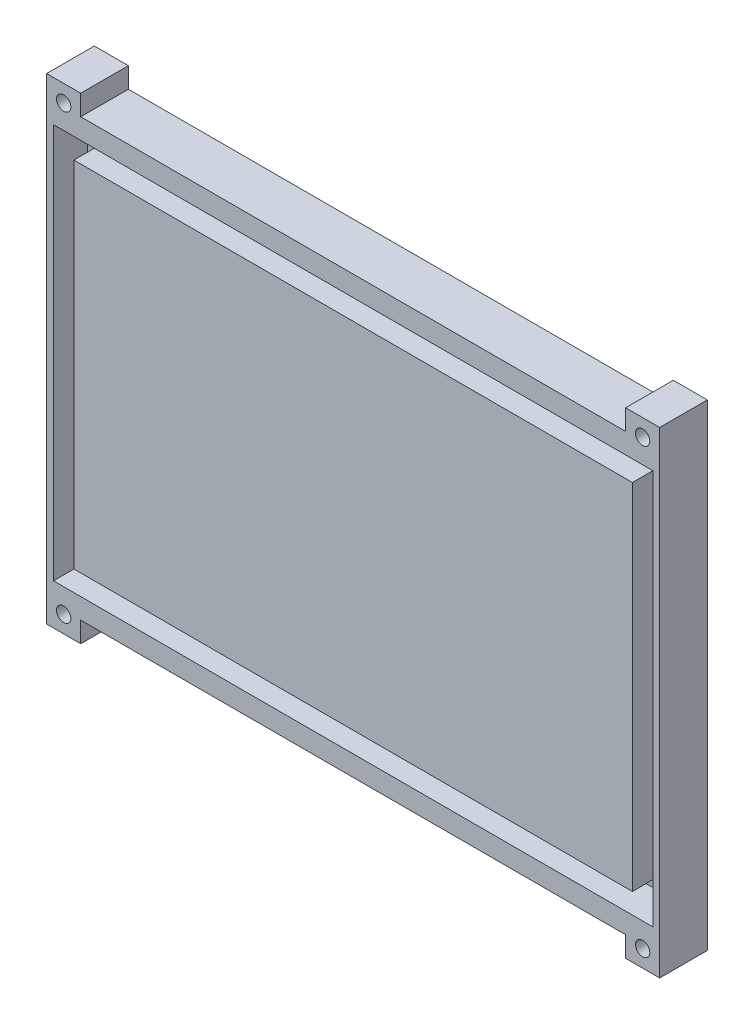
from build123d import *

# Parameters (mm, degrees)
SKETCH_1_W           = 100
SKETCH_1_H           = 70
EXTRUDE_1_DEPTH      = 10
SKETCH_6_W           = 5
SKETCH_6_H           = 5
CUT_EXTRUDE_4_DEPTH  = 5
SKETCH_7_W           = 5
SKETCH_7_H           = 5
CUT_EXTRUDE_5_DEPTH  = 3
SKETCH_8_R           = 1.05
CUT_EXTRUDE_6_DEPTH  = 42
SKETCH_10_W          = 100
SKETCH_10_H          = 70
CUT_EXTRUDE_7_DEPTH  = 3
SKETCH_11_W          = 7
SKETCH_11_H          = 70
CUT_EXTRUDE_8_DEPTH  = 5
SKETCH_12_W          = 7
SKETCH_12_H          = 70
CUT_EXTRUDE_9_DEPTH  = 5
SKETCH_15_W          = 88
SKETCH_15_H          = 58
SKETCH_15_W_2        = 82
SKETCH_15_H_2        = 52
CUT_EXTRUDE_12_DEPTH = 5
SKETCH_16_W          = 5
SKETCH_16_H          = 5
SKETCH_16_R          = 1.05
EXTRUDE_2_DEPTH      = 5
SKETCH_18_W          = 80
SKETCH_18_H          = 3
CUT_EXTRUDE_13_DEPTH = 10


with BuildPart() as part:
    # 草圖1 → 填料-伸長1 (new body)
    with BuildSketch(Plane.XY):
        with Locations((-39.08671555, 7.98136646)):
            Rectangle(SKETCH_1_W, SKETCH_1_H)
    extrude(amount=EXTRUDE_1_DEPTH)

    # 草圖6 → 除料-伸長4 (cut)
    with BuildSketch(Plane.XY.offset(10)):
        with Locations((3.41328445, 40.48136646)):
            Rectangle(SKETCH_6_W, SKETCH_6_H)
        with Locations((-81.58671555, 40.48136646)):
            Rectangle(SKETCH_6_W, SKETCH_6_H)
        with Locations((-81.58671555, -24.51863354)):
            Rectangle(SKETCH_6_W, SKETCH_6_H)
        with Locations((3.41328445, -24.51863354)):
            Rectangle(SKETCH_6_W, SKETCH_6_H)
    extrude(amount=-CUT_EXTRUDE_4_DEPTH, mode=Mode.SUBTRACT)

    # 草圖7 → 除料-伸長5 (cut)
    with BuildSketch(Plane(origin=(0, 0, 0), x_dir=(-1, 0, 0), z_dir=(0, 0, -1))):
        with Locations((81.58671555, 40.48136646)):
            Rectangle(SKETCH_7_W, SKETCH_7_H)
        with Locations((-3.41328445, 40.48136646)):
            Rectangle(SKETCH_7_W, SKETCH_7_H)
        with Locations((81.58671555, -24.51863354)):
            Rectangle(SKETCH_7_W, SKETCH_7_H)
        with Locations((-3.41328445, -24.51863354)):
            Rectangle(SKETCH_7_W, SKETCH_7_H)
    extrude(amount=-CUT_EXTRUDE_5_DEPTH, mode=Mode.SUBTRACT)

    # 草圖8 → 除料-伸長6 (cut)
    with BuildSketch(Plane(origin=(0, 0, 0), x_dir=(-1, 0, 0), z_dir=(0, 0, -1))):
        with Locations((-3.41328445, 40.48136646)):
            Circle(SKETCH_8_R)
        with Locations(Location((81.58671555, 40.48136646, 0), (0, 0, 180))):
            Circle(SKETCH_8_R)
        with Locations((81.58671555, -24.51863354)):
            Circle(SKETCH_8_R)
        with Locations((-3.41328445, -24.51863354)):
            Circle(SKETCH_8_R)
    extrude(amount=-CUT_EXTRUDE_6_DEPTH, mode=Mode.SUBTRACT)

    # 草圖10 → 除料-伸長7 (cut)
    with BuildSketch(Plane.XY):
        with Locations((-39.08671555, 7.98136646)):
            Rectangle(SKETCH_10_W, SKETCH_10_H)
    extrude(amount=CUT_EXTRUDE_7_DEPTH, mode=Mode.SUBTRACT)

    # 草圖11 → 除料-伸長8 (cut)
    with BuildSketch(Plane(origin=(10.91328445, 0, 0), x_dir=(0, 0, -1), z_dir=(1, 0, 0))):
        with Locations((-6.5, 7.98136646)):
            Rectangle(SKETCH_11_W, SKETCH_11_H)
    extrude(amount=-CUT_EXTRUDE_8_DEPTH, mode=Mode.SUBTRACT)

    # 草圖12 → 除料-伸長9 (cut)
    with BuildSketch(Plane.ZY.offset(89.08671555)):
        with Locations((6.5, 7.98136646)):
            Rectangle(SKETCH_12_W, SKETCH_12_H)
    extrude(amount=-CUT_EXTRUDE_9_DEPTH, mode=Mode.SUBTRACT)

    # 草圖15 → 除料-伸長12 (cut)
    with BuildSketch(Plane.XY.offset(10)):
        with Locations((-39.08671555, 7.98136646)):
            Rectangle(SKETCH_15_W, SKETCH_15_H)
        with Locations((-39.08671555, 7.98136646)):
            Rectangle(SKETCH_15_W_2, SKETCH_15_H_2, mode=Mode.SUBTRACT)
    extrude(amount=-CUT_EXTRUDE_12_DEPTH, mode=Mode.SUBTRACT)

    # 草圖16 → 填料-伸長2 (add)
    with BuildSketch(Plane.XY.offset(5)):
        with Locations((-81.58671555, 40.48136646)):
            Rectangle(SKETCH_16_W, SKETCH_16_H)
        with Locations((-81.58671555, 40.48136646)):
            Circle(SKETCH_16_R, mode=Mode.SUBTRACT)
        with Locations((3.41328445, 40.48136646)):
            Rectangle(SKETCH_16_W, SKETCH_16_H)
        with Locations(Location((3.41328445, 40.48136646, 0), (0, 0, 180))):
            Circle(SKETCH_16_R, mode=Mode.SUBTRACT)
        with Locations((3.41328445, -24.51863354)):
            Rectangle(SKETCH_16_W, SKETCH_16_H)
        with Locations((3.41328445, -24.51863354)):
            Circle(SKETCH_16_R, mode=Mode.SUBTRACT)
        with Locations((-81.58671555, -24.51863354)):
            Rectangle(SKETCH_16_W, SKETCH_16_H)
        with Locations(Location((-81.58671555, -24.51863354, 0), (0, 0, 180))):
            Circle(SKETCH_16_R, mode=Mode.SUBTRACT)
    extrude(amount=EXTRUDE_2_DEPTH)

    # 草圖18 → 除料-伸長13 (cut)
    with BuildSketch(Plane.XY.offset(10)):
        with Locations((-39.08671555, 41.48136646)):
            Rectangle(SKETCH_18_W, SKETCH_18_H)
        with Locations((-39.08671555, -25.51863354)):
            Rectangle(SKETCH_18_W, SKETCH_18_H)
    extrude(amount=-CUT_EXTRUDE_13_DEPTH, mode=Mode.SUBTRACT)


solid = part.part
